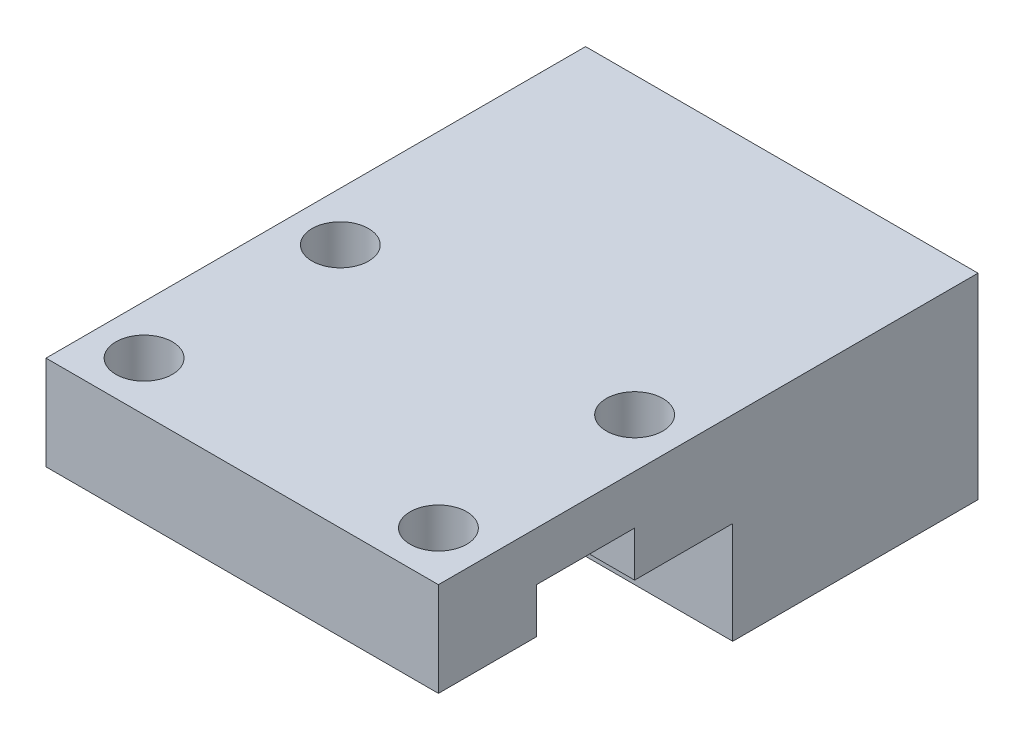
from build123d import *

# Parameters (mm, degrees)
BOSS_EXTRUDE1_DEPTH = 25.4
SKETCH2_R           = 1.8288
CUT_EXTRUDE1_DEPTH  = 12.7
SKETCH3_R           = 1.8288
CUT_EXTRUDE2_DEPTH  = 12.7


with BuildPart() as part:
    # Sketch1 → Boss-Extrude1 (new body)
    with BuildSketch(Plane(origin=(0, 0, 0), x_dir=(0, 0, -1), z_dir=(1, 0, 0))):
        Polygon((0, 6.096), (0, 0), (6.35, 0), (6.35, 2.921), (12.7, 2.921), (12.7, 0), (19.05, 0), (19.05, -6.604), (34.925, -6.604), (34.925, 6.096), align=None)
    extrude(amount=BOSS_EXTRUDE1_DEPTH)

    # Sketch2 → Cut-Extrude1 (cut)
    with BuildSketch(Plane(origin=(0, 0, -34.925), x_dir=(-1, 0, 0), z_dir=(0, 0, -1))):
        with Locations((-19.05, 2.921)):
            Circle(SKETCH2_R)
        with Locations((-6.35, 2.921)):
            Circle(SKETCH2_R)
        with Locations((-19.05, -3.429)):
            Circle(SKETCH2_R)
        with Locations((-6.35, -3.429)):
            Circle(SKETCH2_R)
    extrude(amount=-CUT_EXTRUDE1_DEPTH, mode=Mode.SUBTRACT)

    # Sketch3 → Cut-Extrude2 (cut)
    with BuildSketch(Plane.XZ):
        with Locations((3.175, -3.175)):
            Circle(SKETCH3_R)
        with Locations((3.175, -15.875)):
            Circle(SKETCH3_R)
        with Locations((22.225, -3.175)):
            Circle(SKETCH3_R)
        with Locations((22.225, -15.875)):
            Circle(SKETCH3_R)
    extrude(amount=-CUT_EXTRUDE2_DEPTH, mode=Mode.SUBTRACT)


solid = part.part
